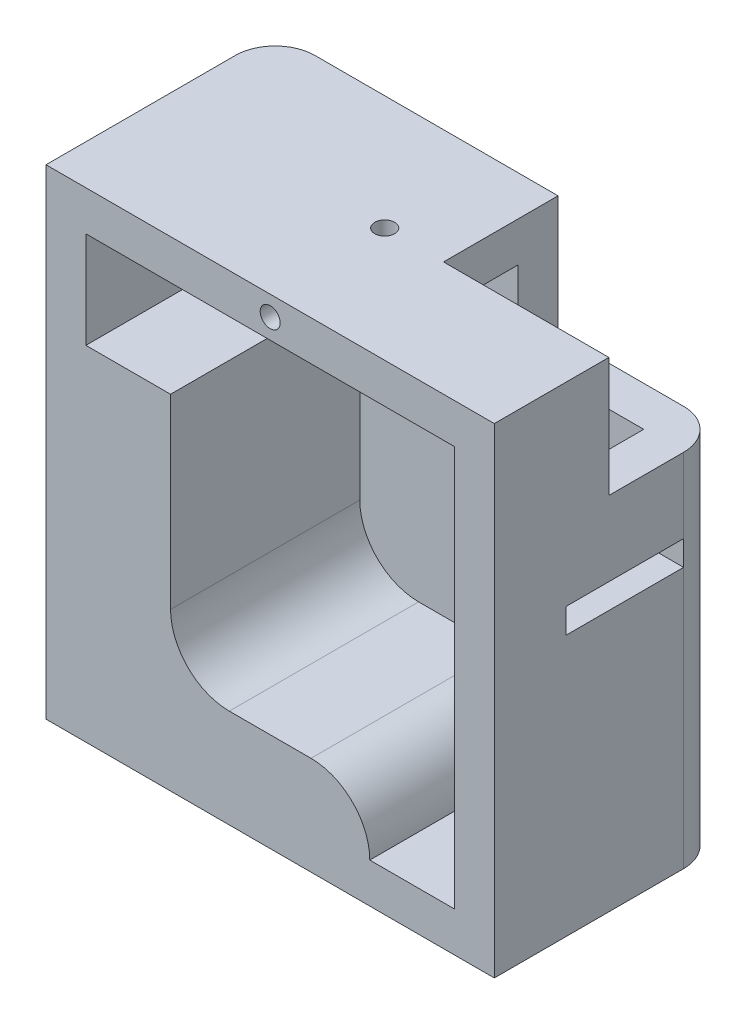
from build123d import *

# Parameters (mm, degrees)
CROQUIS1_W                        = 23
CROQUIS1_H                        = 48.2
SALIENTE_EXTRUIR1_DEPTH           = 22.5
VACIADO1_T                        = -4
CORTAR_EXTRUIR1_START             = -9.2
CORTAR_EXTRUIR1_DEPTH             = 3.5
REDONDEO1_R                       = 4
CROQUIS3_W                        = 11.8
CROQUIS3_H                        = 2.5
CORTAR_EXTRUIR2_DEPTH             = 23.5
CORTAR_EXTRUIR2_DEPTH_BACK        = 23.5
CORTAR_EXTRUIR3_REACH             = 50.2
CROQUIS4_R                        = 1
CORTAR_EXTRUIR3_DIRECTION_2_DEPTH = 1
CROQUIS5_R                        = 1
CORTAR_EXTRUIR4_DEPTH             = 5
SALIENTE_EXTRUIR2_REACH           = 25
CORTAR_EXTRUIR5_START             = -12
CORTAR_EXTRUIR5_DEPTH             = 13
SALIENTE_EXTRUIR3_REACH           = 25


with BuildPart() as part:
    # Croquis1 → Saliente-Extruir1 (new body, symmetric)
    with BuildSketch(Plane(origin=(0, 0, 0), x_dir=(0, 0, -1), z_dir=(1, 0, 0))):
        Rectangle(CROQUIS1_W, CROQUIS1_H)
    extrude(amount=SALIENTE_EXTRUIR1_DEPTH, both=True)

    # Vaciado1
    vaciado1_openings = [part.faces().sort_by_distance(p)[0] for p in [
        (0, 0, 11.5),
    ]]
    offset(amount=VACIADO1_T, openings=vaciado1_openings, kind=Kind.INTERSECTION)

    # Croquis2 → Cortar-Extruir1 (cut)
    with BuildSketch(Plane(origin=(0, 24.1, 0), x_dir=(1, 0, 0), z_dir=(0, 1, 0)).offset(CORTAR_EXTRUIR1_START)):
        Polygon((-22.5, 11.5), (-5.9, 11.5), (-5.9, 7.5), (-18.5, 7.5), (-18.5, 0), (-22.5, 0), align=None)
        Polygon((18.5, 0), (22.5, 0), (22.5, 11.5), (5.9, 11.5), (5.9, 7.5), (18.5, 7.5), align=None)
    extrude(amount=CORTAR_EXTRUIR1_DEPTH, mode=Mode.SUBTRACT)

    # Redondeo1
    redondeo1_edges = [part.edges().sort_by_distance(p)[0] for p in [
        (-22.5, 21.25, -11.5),
        (22.5, 21.25, -11.5),
        (22.5, -4.6, -11.5),
        (-22.5, -4.6, -11.5),
    ]]
    fillet(redondeo1_edges, radius=REDONDEO1_R)

    # Croquis3 → Cortar-Extruir2 (cut, two sides)
    with BuildSketch(Plane(origin=(0, 0, 0), x_dir=(0, 0, -1), z_dir=(1, 0, 0))) as cortar_extruir2_sk:
        with Locations((1.6, 3.35)):
            Rectangle(CROQUIS3_W, CROQUIS3_H)
    extrude(amount=CORTAR_EXTRUIR2_DEPTH, mode=Mode.SUBTRACT)
    extrude(cortar_extruir2_sk.sketch, amount=-CORTAR_EXTRUIR2_DEPTH_BACK, mode=Mode.SUBTRACT)

    # Croquis4 → Cortar-Extruir3 (cut, up to next)
    with BuildSketch(Plane(origin=(0, 24.1, 0), x_dir=(1, 0, 0), z_dir=(0, 1, 0)), mode=Mode.PRIVATE) as cortar_extruir3_sk1:
        Circle(CROQUIS4_R)
    cortar_extruir3_tool1 = extrude(cortar_extruir3_sk1.sketch, amount=-CORTAR_EXTRUIR3_REACH, mode=Mode.PRIVATE) & part.part
    add(cortar_extruir3_tool1.solids().sort_by_distance((0, 24.1, 0))[0], mode=Mode.SUBTRACT)

    # Croquis4 → Cortar-Extruir3 direction 2 (cut)
    with BuildSketch(Plane(origin=(0, 24.1, 0), x_dir=(1, 0, 0), z_dir=(0, 1, 0))):
        Circle(CROQUIS4_R)
    extrude(amount=CORTAR_EXTRUIR3_DIRECTION_2_DEPTH, mode=Mode.SUBTRACT)

    # Croquis5 → Cortar-Extruir4 (cut)
    with BuildSketch(Plane.XY.offset(11.5)):
        with Locations((0, 22.1)):
            Circle(CROQUIS5_R)
    extrude(amount=-CORTAR_EXTRUIR4_DEPTH, mode=Mode.SUBTRACT)

    # Croquis6 → Saliente-Extruir2 (add, up to next)
    with BuildSketch(Plane.XY.offset(11.5), mode=Mode.PRIVATE) as saliente_extruir2_sk1:
        with BuildLine():
            Line((-10, -20.1), (10, -20.1))
            ThreePointArc((10, -20.1), (8.271930009, -15.928069991), (4.1, -14.2))
            Line((4.1, -14.2), (-4.1, -14.2))
            ThreePointArc((-4.1, -14.2), (-8.271930009, -15.928069991), (-10, -20.1))
        make_face()
    saliente_extruir2_tool1 = extrude(saliente_extruir2_sk1.sketch, amount=-SALIENTE_EXTRUIR2_REACH, mode=Mode.PRIVATE) - part.part
    add(saliente_extruir2_tool1.solids().sort_by_distance((0, -17.386611, 11.5))[0])

    # Croquis7 → Cortar-Extruir5 (cut, through all)
    with BuildSketch(Plane(origin=(0, 24.1, 0), x_dir=(1, 0, 0), z_dir=(0, 1, 0)).offset(CORTAR_EXTRUIR5_START)):
        with BuildLine():
            Line((5.9, 7.5), (5.9, 0))
            Line((5.9, 0), (18.5, 0))
            Line((18.5, 0), (22.5, 0))
            Line((22.5, 0), (22.5, 7.5))
            ThreePointArc((22.5, 7.5), (21.328427125, 10.328427125), (18.5, 11.5))
            Line((18.5, 11.5), (5.9, 11.5))
            Line((5.9, 11.5), (5.9, 7.5))
        make_face()
    extrude(amount=CORTAR_EXTRUIR5_DEPTH, mode=Mode.SUBTRACT)

    # Croquis8 → Saliente-Extruir3 (add, up to next)
    with BuildSketch(Plane.XY.offset(11.5), mode=Mode.PRIVATE) as saliente_extruir3_sk1:
        with BuildLine():
            Line((-18.5, -20.1), (-18.5, 10.4))
            Line((-18.5, 10.4), (-10, 10.4))
            Line((-10, 10.4), (-10, -8.3))
            ThreePointArc((-10, -8.3), (-8.271930009, -12.471930009), (-4.1, -14.2))
            ThreePointArc((-4.1, -14.2), (-8.271930009, -15.928069991), (-10, -20.1))
            Line((-10, -20.1), (-18.5, -20.1))
        make_face()
    saliente_extruir3_tool1 = extrude(saliente_extruir3_sk1.sketch, amount=-SALIENTE_EXTRUIR3_REACH, mode=Mode.PRIVATE) - part.part
    add(saliente_extruir3_tool1.solids().sort_by_distance((-13.946608, -5.359479, 11.5))[0])


solid = part.part
